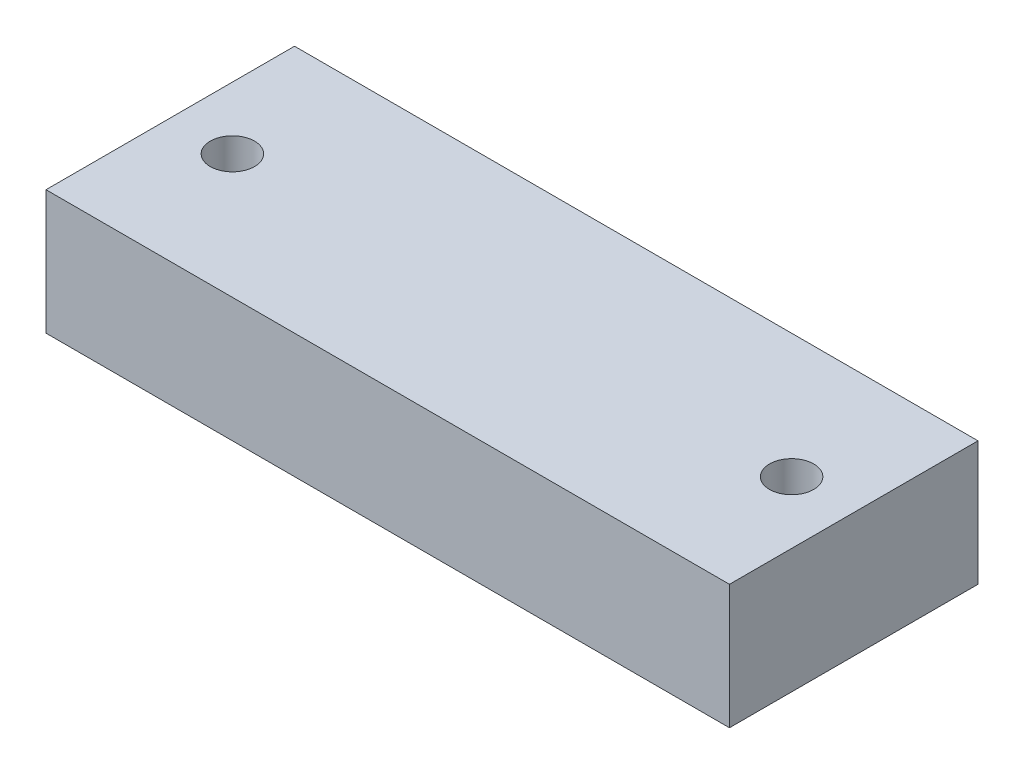
from build123d import *

# Parameters (mm, degrees)
SKETCH1_W             = 34.925
SKETCH1_H             = 12.7
BOSS_EXTRUDE1_DEPTH   = 6.35
F_4_40_TAPPED_HOLE1_D = 2.2606


with BuildPart() as part:
    # Sketch1 → Boss-Extrude1 (new body)
    with BuildSketch(Plane(origin=(0, 0, 0), x_dir=(1, 0, 0), z_dir=(0, 1, 0))):
        Rectangle(SKETCH1_W, SKETCH1_H)
    extrude(amount=BOSS_EXTRUDE1_DEPTH)

    # #4-40 Tapped Hole1 (through all)
    with Locations(Plane(origin=(0, 6.35, 0), x_dir=(1, 0, 0), z_dir=(0, 1, 0))):
        with Locations((-14.2875, 0), (14.2875, 0)):
            Hole(F_4_40_TAPPED_HOLE1_D / 2)


solid = part.part
